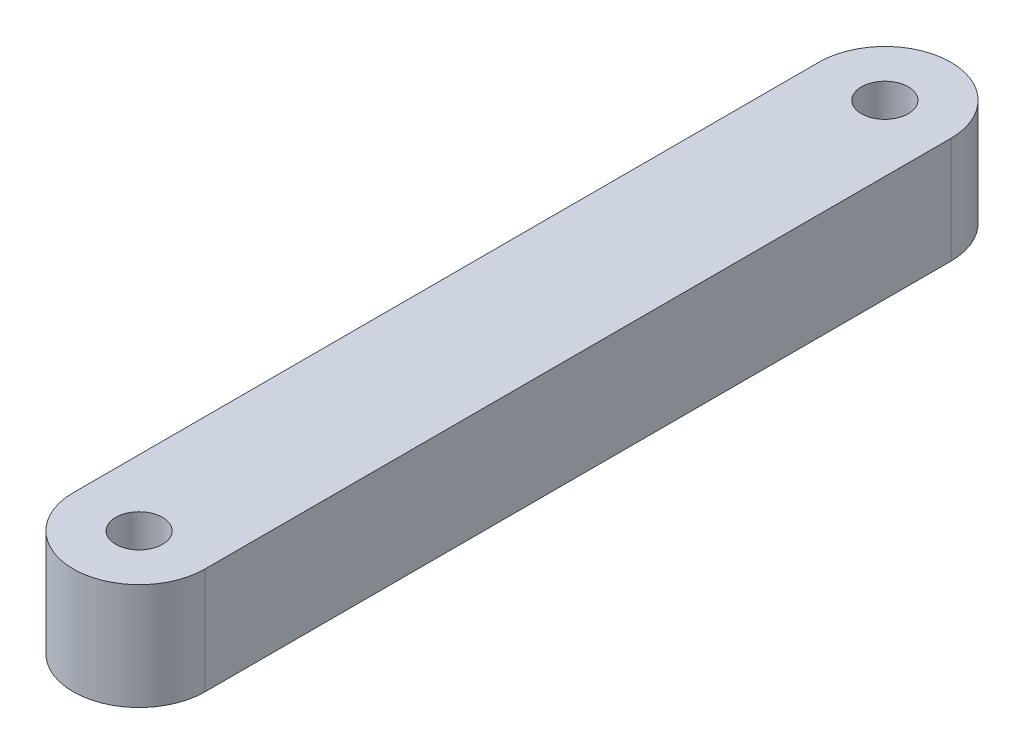
from build123d import *

# Parameters (mm, degrees)
SKETCH1_R           = 1.1
BOSS_EXTRUDE1_DEPTH = 5


with BuildPart() as part:
    # Sketch1 → Boss-Extrude1 (new body)
    with BuildSketch(Plane(origin=(0, 0, 0), x_dir=(1, 0, 0), z_dir=(0, 1, 0))):
        with BuildLine():
            Line((-3.1, -17.52), (-3.1, 17.52))
            ThreePointArc((-3.1, 17.52), (0, 20.62), (3.1, 17.52))
            Line((3.1, 17.52), (3.1, -17.52))
            ThreePointArc((3.1, -17.52), (0, -20.62), (-3.1, -17.52))
        make_face()
        with Locations((0, 17.52)):
            Circle(SKETCH1_R, mode=Mode.SUBTRACT)
        with Locations((0, -17.52)):
            Circle(SKETCH1_R, mode=Mode.SUBTRACT)
    extrude(amount=BOSS_EXTRUDE1_DEPTH)


solid = part.part
